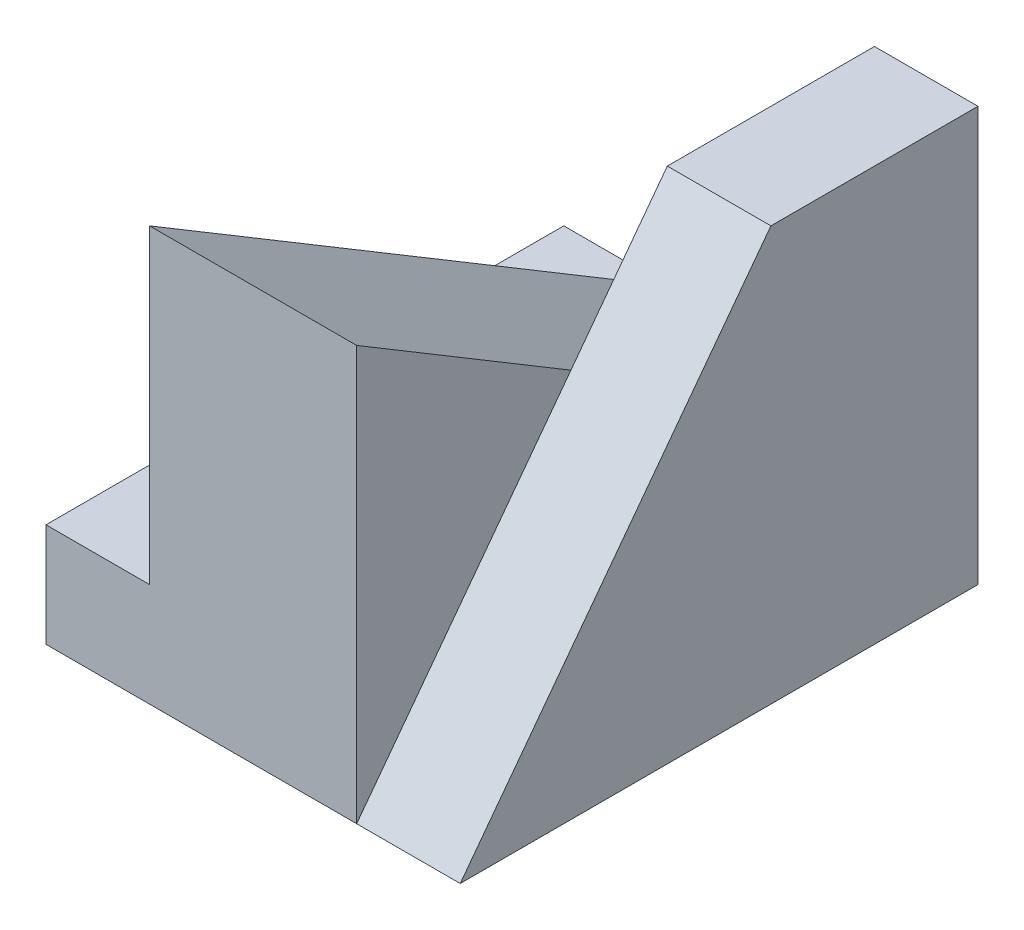
from build123d import *

# Parameters (mm, degrees)
BOSS_EXTRUDE1_DEPTH = 1
BOSS_EXTRUDE2_DEPTH = 2
SKETCH3_W           = 5
SKETCH3_H           = 1
BOSS_EXTRUDE3_DEPTH = 1


with BuildPart() as part:
    # Sketch1 → Boss-Extrude1 (new body)
    with BuildSketch(Plane(origin=(0, 0, 0), x_dir=(0, 0, -1), z_dir=(1, 0, 0))):
        Polygon((0, 0), (0, 4), (-2, 4), (-5, 0), align=None)
    extrude(amount=BOSS_EXTRUDE1_DEPTH)

    # Sketch2 → Boss-Extrude2 (add)
    with BuildSketch(Plane.ZY):
        Polygon((0, 0), (5, 0), (5, 4), (0, 1), align=None)
    extrude(amount=BOSS_EXTRUDE2_DEPTH)

    # Sketch3 → Boss-Extrude3 (add)
    with BuildSketch(Plane.ZY.offset(2)):
        with Locations((2.5, 0.5)):
            Rectangle(SKETCH3_W, SKETCH3_H)
    extrude(amount=BOSS_EXTRUDE3_DEPTH)


solid = part.part
